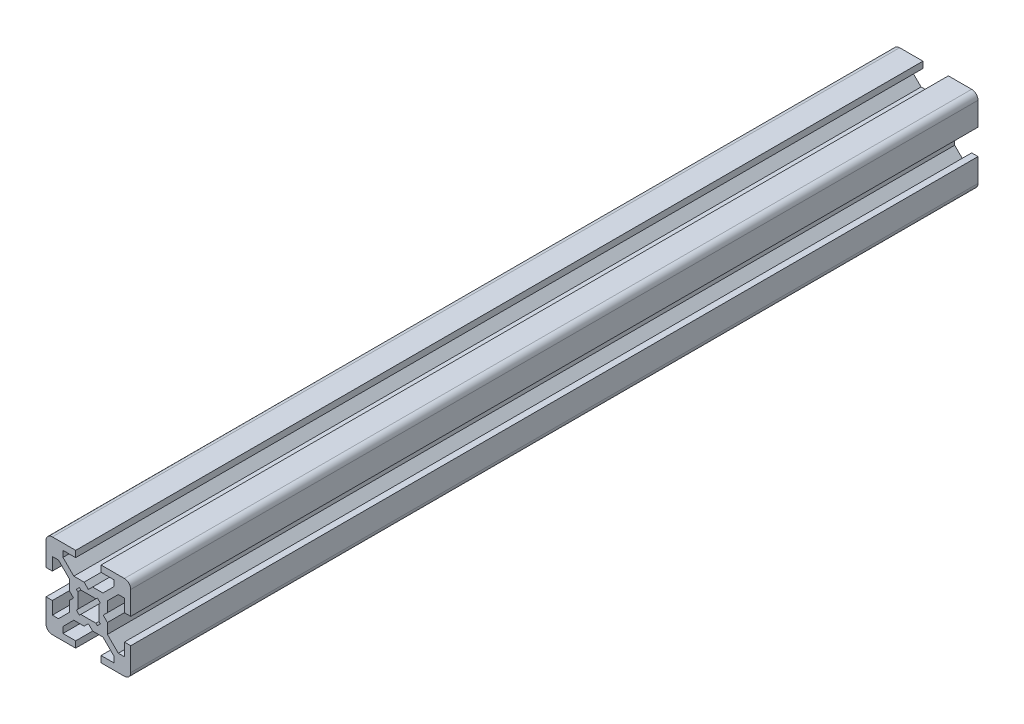
from build123d import *

# Parameters (mm, degrees)
BOSS_EXTRUDE1_DEPTH = 200
FILLET1_R           = 1.5


with BuildPart() as part:
    # Sketch1 → Boss-Extrude1 (new body)
    with BuildSketch(Plane.XY):
        Polygon((0, 3.5), (1, 4.5), (3.439339828, 4.5), (6, 7.060660172), (6, 8.5), (3, 8.5), (3, 10), (10, 10), (10, 3), (8.5, 3), (8.5, 6), (7.060660172, 6), (4.5, 3.439339828), (4.5, 1), (3.5, 0), (4.5, -1), (4.5, -3.439339828), (7.060660172, -6), (8.5, -6), (8.5, -3), (10, -3), (10, -10), (3, -10), (3, -8.5), (6, -8.5), (6, -7.060660172), (3.439339828, -4.5), (1, -4.5), (0, -3.5), (-1, -4.5), (-3.439339828, -4.5), (-6, -7.060660172), (-6, -8.5), (-3, -8.5), (-3, -10), (-10, -10), (-10, -3), (-8.5, -3), (-8.5, -6), (-7.060660172, -6), (-4.5, -3.439339828), (-4.5, -1), (-3.5, 0), (-4.5, 1), (-4.5, 3.439339828), (-7.060660172, 6), (-8.5, 6), (-8.5, 3), (-10, 3), (-10, 10), (-3, 10), (-3, 8.5), (-6, 8.5), (-6, 7.060660172), (-3.439339828, 4.5), (-1, 4.5), align=None)
        Polygon((-1.792893219, 2.5), (1.792893219, 2.5), (2.121320344, 2.828427125), (2.828427125, 2.121320344), (2.5, 1.792893219), (2.5, -1.792893219), (2.828427125, -2.121320344), (2.121320344, -2.828427125), (1.792893219, -2.5), (-1.792893219, -2.5), (-2.121320344, -2.828427125), (-2.828427125, -2.121320344), (-2.5, -1.792893219), (-2.5, 1.792893219), (-2.828427125, 2.121320344), (-2.121320344, 2.828427125), align=None, mode=Mode.SUBTRACT)
    extrude(amount=BOSS_EXTRUDE1_DEPTH)

    # Fillet1
    fillet1_edges = [part.edges().sort_by_distance(p)[0] for p in [
        (10, 10, 100),
        (10, -10, 100),
        (-10, -10, 100),
        (-10, 10, 100),
    ]]
    fillet(fillet1_edges, radius=FILLET1_R)


solid = part.part
